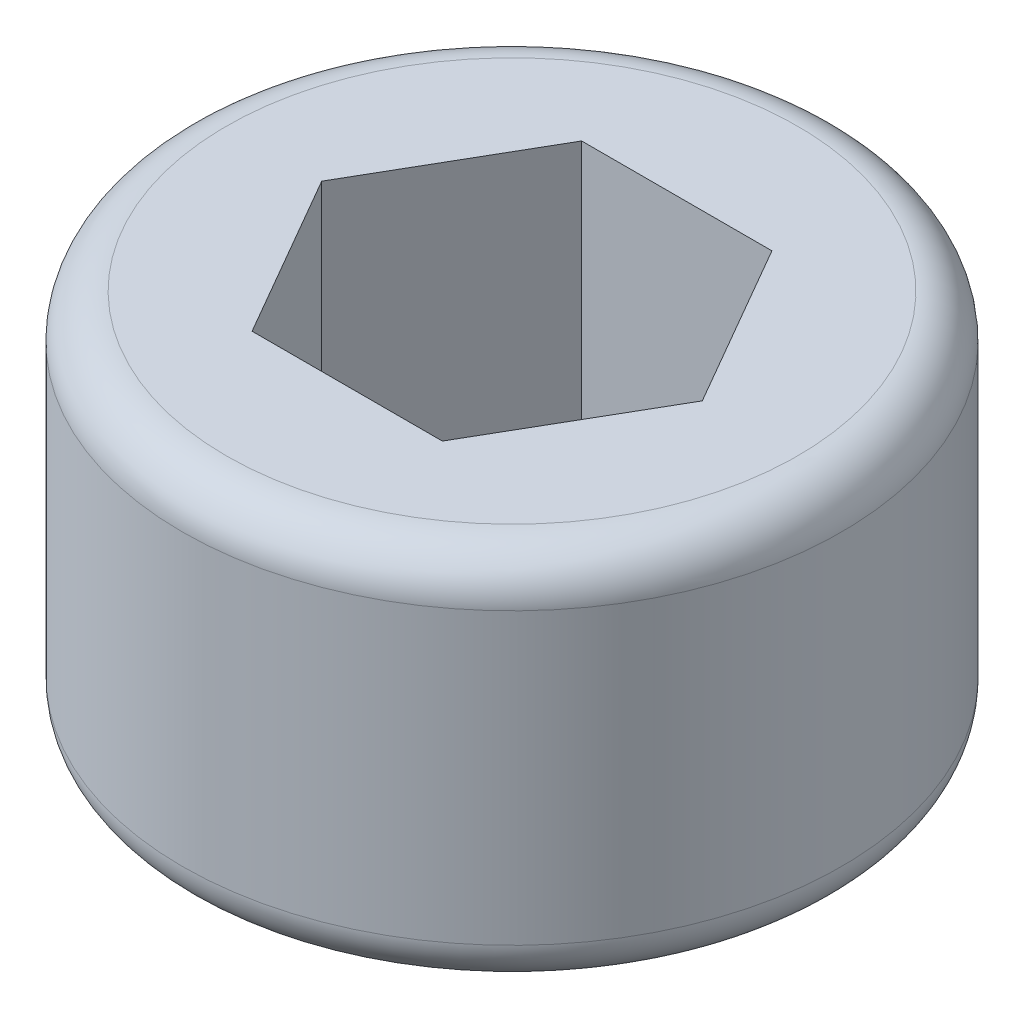
from build123d import *

# Parameters (mm, degrees)
SKETCH_1_R            = 1.5
EXTRUDE_254_DEPTH     = 2
CUT_EXTRUDE_388_DEPTH = 1.2
FILLET_1_R            = 0.2


with BuildPart() as part:
    # 草图1 → Extrude 254 (new body)
    with BuildSketch(Plane(origin=(0, 0, 0), x_dir=(1, 0, 0), z_dir=(0, 1, 0))):
        Circle(SKETCH_1_R)
    extrude(amount=EXTRUDE_254_DEPTH)

    # 草图2 → Cut-Extrude 388 (cut)
    with BuildSketch(Plane(origin=(0, 2, 0), x_dir=(1, 0, 0), z_dir=(0, 1, 0))):
        Polygon((0.866025404, 0), (0.433012702, 0.75), (-0.433012702, 0.75), (-0.866025404, 0), (-0.433012702, -0.75), (0.433012702, -0.75), align=None)
    extrude(amount=-CUT_EXTRUDE_388_DEPTH, mode=Mode.SUBTRACT)

    # 草图3 → 切除-旋转4 (revolve, cut)
    with BuildSketch(Plane.XY):
        Polygon((0.866025404, 0), (1.5, 0.366025404), (1.5, 0), align=None)
    revolve(axis=Axis((0, 2, 0), (0, -1, 0)), mode=Mode.SUBTRACT)

    # 圆角1
    fillet_1_edges = [part.edges().sort_by_distance(p)[0] for p in [
        (-1.5, 0.366025404, 0),
        (-1.5, 2, 0),
    ]]
    fillet(fillet_1_edges, radius=FILLET_1_R)


solid = part.part
